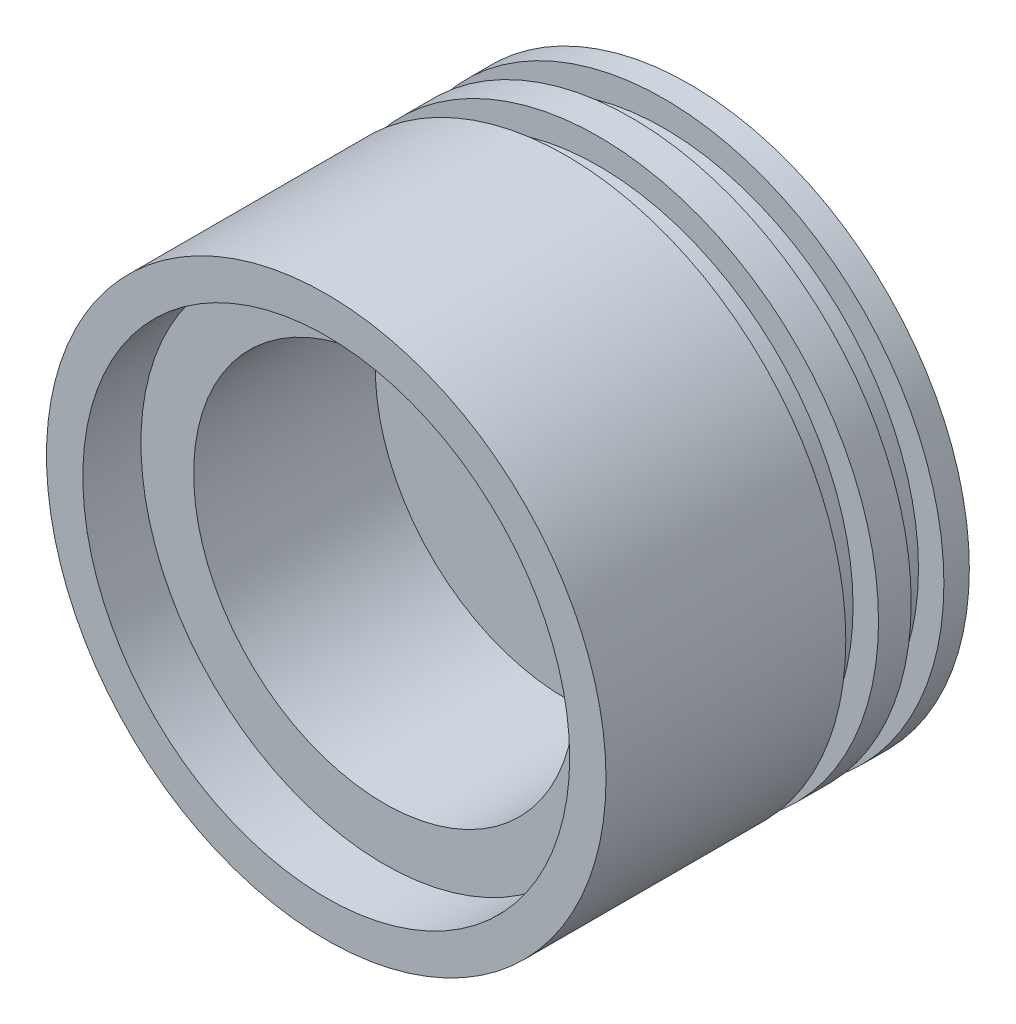
from build123d import *


with BuildPart() as part:
    # Sketch1 → Revolve7 (revolve)
    with BuildSketch(Plane(origin=(0, 0, 0), x_dir=(1, 0, 0), z_dir=(0, 1, 0))):
        with BuildLine():
            Line((0, 66), (0, 110))
            ThreePointArc((0, 110), (38.823317736, 107.489546564), (77, 100))
            Line((77, 100), (77, 93))
            Line((77, 93), (70, 93))
            Line((70, 93), (70, 84))
            Line((70, 84), (77, 84))
            Line((77, 84), (77, 75))
            Line((77, 75), (70, 75))
            Line((70, 75), (70, 66))
            Line((70, 66), (77, 66))
            Line((77, 66), (77, 0))
            Line((77, 0), (67, 0))
            Line((67, 0), (67, 16))
            Line((67, 16), (52.5, 16))
            Line((52.5, 16), (52.5, 66))
            Line((52.5, 66), (0, 66))
        make_face()
    revolve(axis=Axis((0, 0, 14.193325573), (0, 0, -1)))


solid = part.part
